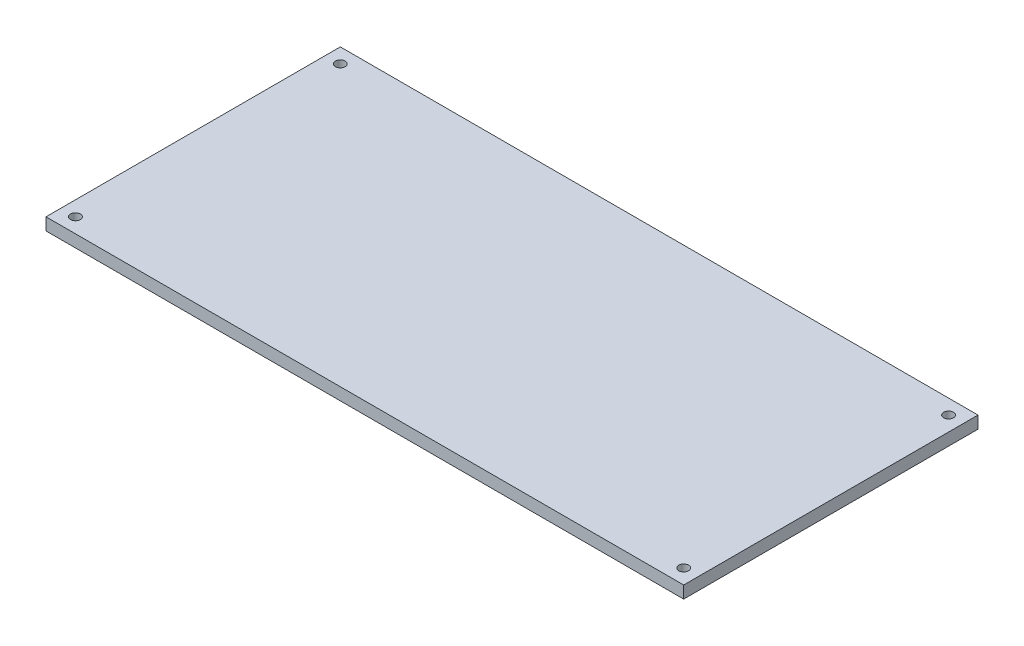
from build123d import *

# Parameters (mm, degrees)
SKETCH3_W           = 130
SKETCH3_H           = 60
BOSS_EXTRUDE1_DEPTH = 2.5
CUT_EXTRUDE1_REACH  = 4.5
SKETCH4_R           = 1


with BuildPart() as part:
    # Sketch3 → Boss-Extrude1 (new body)
    with BuildSketch(Plane(origin=(0, 0, 0), x_dir=(1, 0, 0), z_dir=(0, 1, 0))):
        Rectangle(SKETCH3_W, SKETCH3_H)
    extrude(amount=BOSS_EXTRUDE1_DEPTH)

    # Sketch4 → Cut-Extrude1 (cut, up to next)
    with BuildSketch(Plane(origin=(0, 2.5, 0), x_dir=(1, 0, 0), z_dir=(0, 1, 0)), mode=Mode.PRIVATE) as cut_extrude1_sk1:
        with Locations((-62, 27)):
            Circle(SKETCH4_R)
    cut_extrude1_tool1 = extrude(cut_extrude1_sk1.sketch, amount=-CUT_EXTRUDE1_REACH, mode=Mode.PRIVATE) & part.part
    add(cut_extrude1_tool1.solids().sort_by_distance((-62, 2.5, -27))[0], mode=Mode.SUBTRACT)
    # Sketch4 → Cut-Extrude1 (cut, up to next)
    with BuildSketch(Plane(origin=(0, 2.5, 0), x_dir=(1, 0, 0), z_dir=(0, 1, 0)), mode=Mode.PRIVATE) as cut_extrude1_sk2:
        with Locations((62, 27)):
            Circle(SKETCH4_R)
    cut_extrude1_tool2 = extrude(cut_extrude1_sk2.sketch, amount=-CUT_EXTRUDE1_REACH, mode=Mode.PRIVATE) & part.part
    add(cut_extrude1_tool2.solids().sort_by_distance((62, 2.5, -27))[0], mode=Mode.SUBTRACT)
    # Sketch4 → Cut-Extrude1 (cut, up to next)
    with BuildSketch(Plane(origin=(0, 2.5, 0), x_dir=(1, 0, 0), z_dir=(0, 1, 0)), mode=Mode.PRIVATE) as cut_extrude1_sk3:
        with Locations((62, -27)):
            Circle(SKETCH4_R)
    cut_extrude1_tool3 = extrude(cut_extrude1_sk3.sketch, amount=-CUT_EXTRUDE1_REACH, mode=Mode.PRIVATE) & part.part
    add(cut_extrude1_tool3.solids().sort_by_distance((62, 2.5, 27))[0], mode=Mode.SUBTRACT)
    # Sketch4 → Cut-Extrude1 (cut, up to next)
    with BuildSketch(Plane(origin=(0, 2.5, 0), x_dir=(1, 0, 0), z_dir=(0, 1, 0)), mode=Mode.PRIVATE) as cut_extrude1_sk4:
        with Locations((-62, -27)):
            Circle(SKETCH4_R)
    cut_extrude1_tool4 = extrude(cut_extrude1_sk4.sketch, amount=-CUT_EXTRUDE1_REACH, mode=Mode.PRIVATE) & part.part
    add(cut_extrude1_tool4.solids().sort_by_distance((-62, 2.5, 27))[0], mode=Mode.SUBTRACT)


solid = part.part
